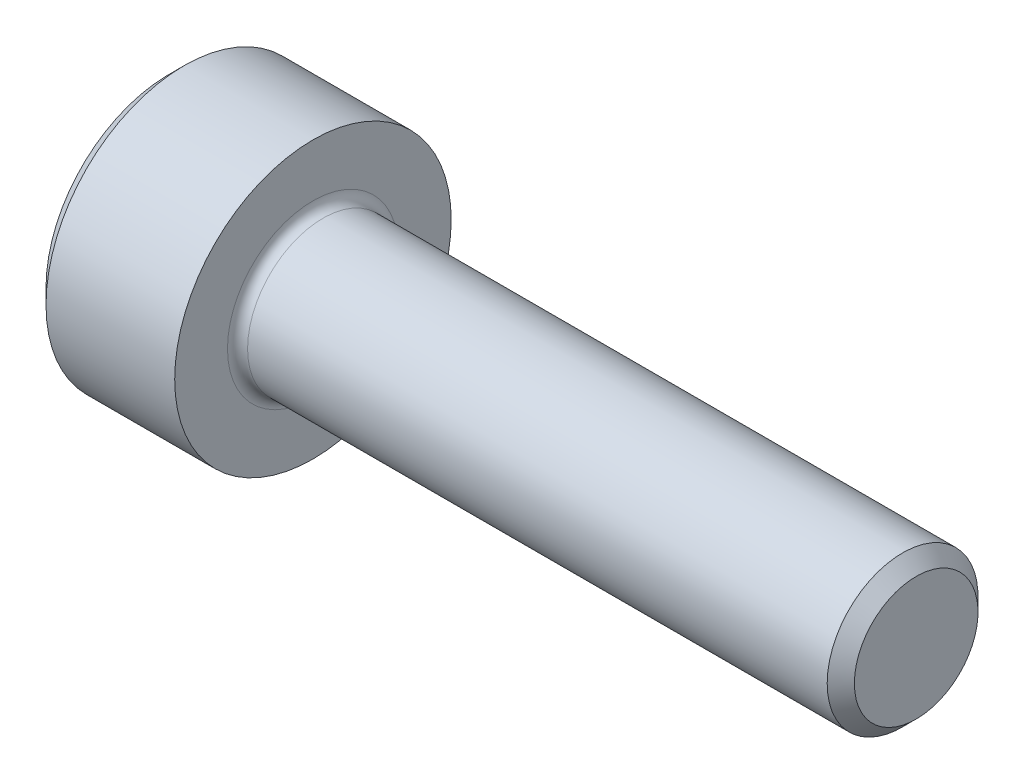
from build123d import *

# Parameters (mm, degrees)
CUT_EXTRUDE1_DEPTH = 1.3


with BuildPart() as part:
    # Sketch1 → Revolve1 (revolve)
    with BuildSketch(Plane.XY):
        with BuildLine():
            Line((-2.86, 0), (-2.86, 2.45))
            Line((-2.86, 2.45), (-2.56, 2.75))
            Line((-2.56, 2.75), (0, 2.75))
            Line((0, 2.75), (0, 1.7))
            ThreePointArc((0, 1.7), (0.058578644, 1.558578644), (0.2, 1.5))
            Line((0.2, 1.5), (11.7295, 1.5))
            Line((11.7295, 1.5), (12, 1.2295))
            Line((12, 1.2295), (12, 0))
            Line((12, 0), (-2.86, 0))
        make_face()
    revolve(axis=Axis((12, 0, 0), (-1, 0, 0)))

    # Sketch2 → Cut-Extrude1 (cut)
    with BuildSketch(Plane(origin=(-2.86, 0, 0), x_dir=(0, 0, -1), z_dir=(1, 0, 0))):
        Polygon((-1.25, 0.721687836), (-1.25, -0.721687836), (0, -1.443375673), (1.25, -0.721687836), (1.25, 0.721687836), (0, 1.443375673), align=None)
    extrude(amount=CUT_EXTRUDE1_DEPTH, mode=Mode.SUBTRACT)

    # Sketch3 → Cut-Revolve1 (revolve, cut)
    with BuildSketch(Plane.XY):
        Polygon((-1.56, 0), (-1.56, 1.25), (-0.838312164, 0), align=None)
    revolve(axis=Axis((-0.838312164, 0, 0), (-1, 0, 0)), mode=Mode.SUBTRACT)


solid = part.part
